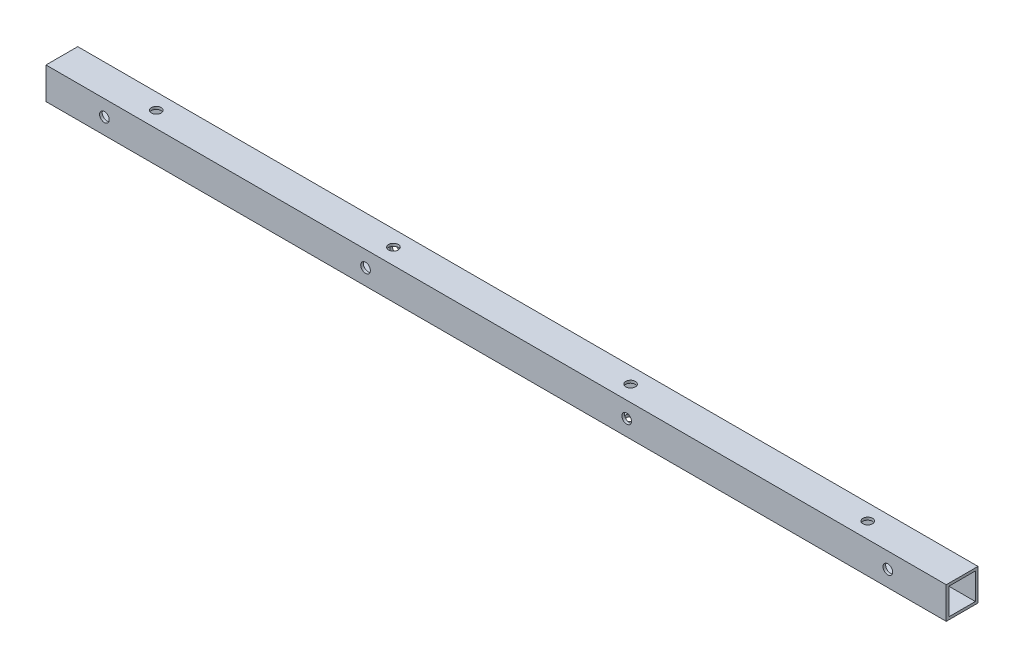
from build123d import *

# Parameters (mm, degrees)
SKETCH1_W               = 19.05
SKETCH1_H               = 19.05
SKETCH1_W_2             = 15.875
SKETCH1_H_2             = 15.875
TUBE_DEPTH              = 539.9532
SKETCH2_R               = 2.8956
REARWALLHOLES_DEPTH     = 20.05
LPATTERN1_COUNT         = 4
LPATTERN1_PITCH         = 156.633333333
SKETCH3_R               = 2.8956
REARTOPHOLEMASTER_DEPTH = 20.05
LPATTERN2_COUNT         = 4
LPATTERN2_PITCH         = 142.24


with BuildPart() as part:
    # Sketch1 → Tube (new body)
    with BuildSketch(Plane(origin=(0, 0, 0), x_dir=(0, -1, 0), z_dir=(1, 0, 0))):
        Rectangle(SKETCH1_W, SKETCH1_H)
        Rectangle(SKETCH1_W_2, SKETCH1_H_2, mode=Mode.SUBTRACT)
    extrude(amount=TUBE_DEPTH)

    # Sketch2 → RearWallHoles (cut, through all)
    with BuildSketch(Plane.XY.offset(9.525)):
        with Locations((504.9266, 0)):
            Circle(SKETCH2_R)
    rearwallholes = extrude(amount=-REARWALLHOLES_DEPTH, mode=Mode.SUBTRACT)

    # LPattern1: RearWallHoles ×4
    with Locations(*[(-i * LPATTERN1_PITCH, 0, 0) for i in range(1, LPATTERN1_COUNT)]):
        add(rearwallholes, mode=Mode.SUBTRACT)

    # Sketch3 → RearTopHoleMaster (cut, through all)
    with BuildSketch(Plane(origin=(0, 9.525, 0), x_dir=(1, 0, 0), z_dir=(0, 1, 0))):
        with Locations((56.6166, 0)):
            Circle(SKETCH3_R)
    reartopholemaster = extrude(amount=-REARTOPHOLEMASTER_DEPTH, mode=Mode.SUBTRACT)

    # LPattern2: RearTopHoleMaster ×4
    with Locations(*[(i * LPATTERN2_PITCH, 0, 0) for i in range(1, LPATTERN2_COUNT)]):
        add(reartopholemaster, mode=Mode.SUBTRACT)


solid = part.part
